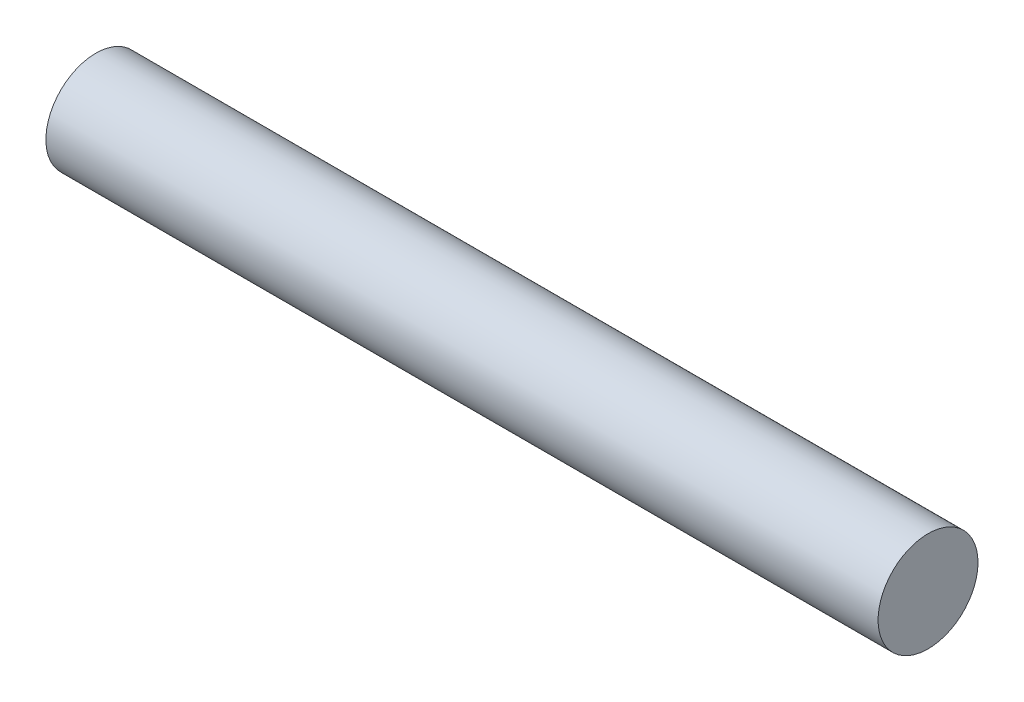
from build123d import *

# Parameters (mm, degrees)
SKETCH1_R           = 2.38125
BOSS_EXTRUDE1_DEPTH = 39.6748


with BuildPart() as part:
    # Sketch1 → Boss-Extrude1 (new body)
    with BuildSketch(Plane(origin=(0, 0, 0), x_dir=(0, 0, -1), z_dir=(1, 0, 0))):
        Circle(SKETCH1_R)
    extrude(amount=BOSS_EXTRUDE1_DEPTH)


solid = part.part
